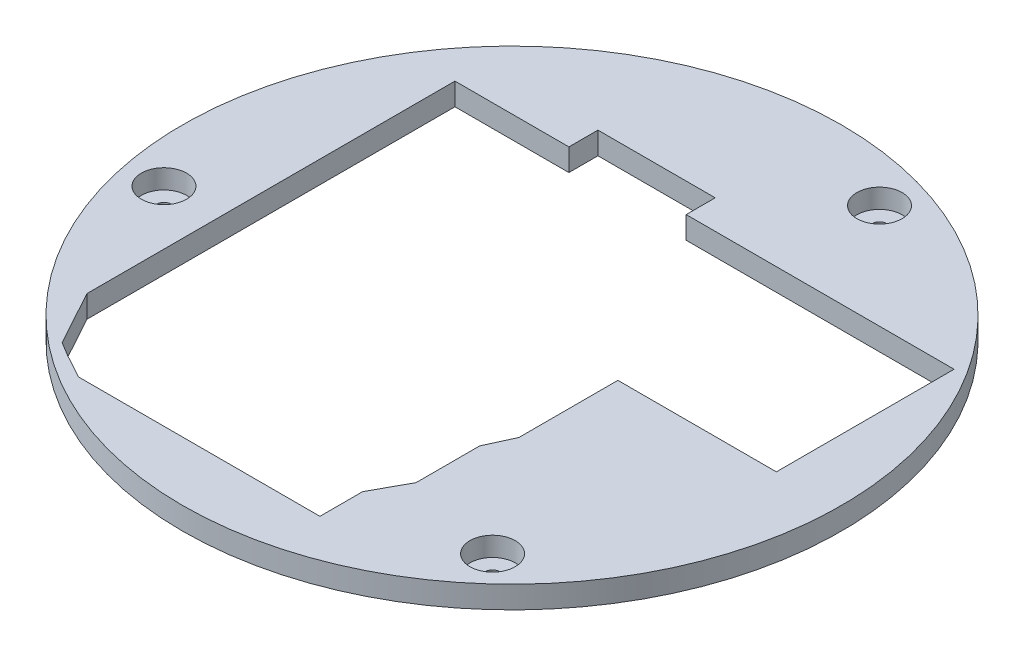
from build123d import *

# Parameters (mm, degrees)
SKETCH2_R           = 44.4
BOSS_EXTRUDE1_DEPTH = 3
CUT_EXTRUDE3_START  = 3
SKETCH3_R           = 3.05
CUT_EXTRUDE3_DEPTH  = 2.6
SKETCH4_R           = 1
CUT_EXTRUDE4_DEPTH  = 1.4


with BuildPart() as part:
    # Sketch2 → Boss-Extrude1 (new body)
    with BuildSketch(Plane(origin=(0, 0, 0), x_dir=(1, 0, 0), z_dir=(0, 1, 0))):
        with Locations((5.844668035, 0)):
            Circle(SKETCH2_R)
        Polygon((-25.306151193, 23.466427606), (-9.956472153, 23.466427606), (-9.956472153, 27.379090891), (5.844668035, 27.379090891), (5.844668035, 23.466427606), (41.936760168, 23.466427606), (41.936760168, -0.473949831), (20.582698865, -0.473949831), (20.582698865, -13.817632751), (18.922929974, -17.433557834), (18.922929974, -26.013051917), (16.376674503, -30.649762231), (16.376674503, -36.409044515), (-16.167559029, -36.409044515), (-19.414149946, -34.62617491), (-21.26171293, -33.507445335), (-22.686577877, -30.901858186), (-25.306151193, -26.111560985), align=None, mode=Mode.SUBTRACT)
    extrude(amount=BOSS_EXTRUDE1_DEPTH)

    # Sketch3 → Cut-Extrude3 (cut)
    with BuildSketch(Plane(origin=(0, 0, 0), x_dir=(1, 0, 0), z_dir=(0, 1, 0)).offset(CUT_EXTRUDE3_START)):
        with Locations((32.364967514, -29.138183119)):
            Circle(SKETCH3_R)
        with Locations((17.818925096, 37.536344625)):
            Circle(SKETCH3_R)
        with Locations((-32.649888507, -8.398161506)):
            Circle(SKETCH3_R)
    extrude(amount=-CUT_EXTRUDE3_DEPTH, mode=Mode.SUBTRACT)

    # Sketch4 → Cut-Extrude4 (cut, through all)
    with BuildSketch(Plane(origin=(0, 0.4, 0), x_dir=(1, 0, 0), z_dir=(0, 1, 0))):
        with Locations((-32.649888507, -8.398161506)):
            Circle(SKETCH4_R)
        with Locations((17.818925096, 37.536344625)):
            Circle(SKETCH4_R)
        with Locations((32.364967514, -29.138183119)):
            Circle(SKETCH4_R)
    extrude(amount=-CUT_EXTRUDE4_DEPTH, mode=Mode.SUBTRACT)


solid = part.part
